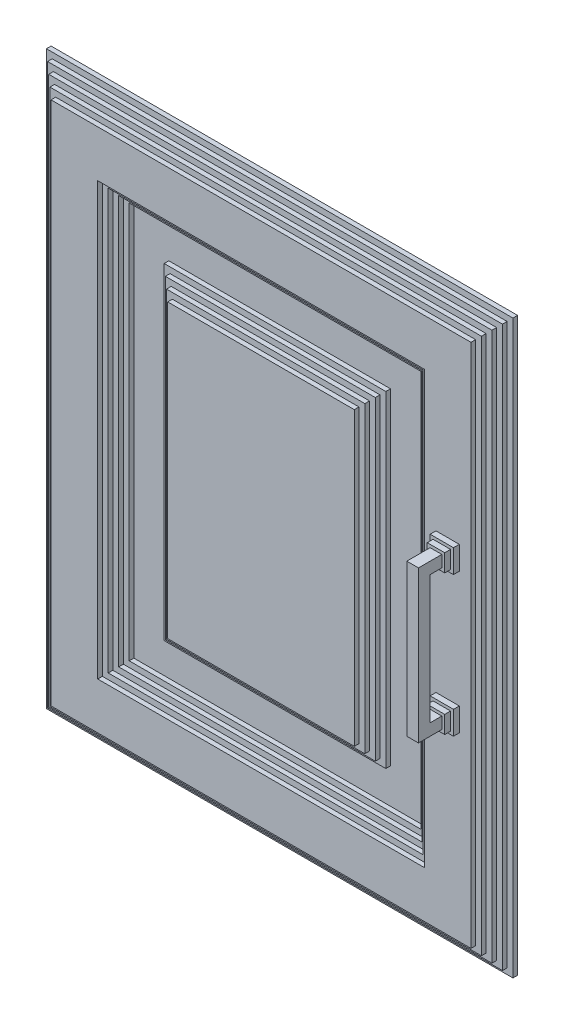
from build123d import *

# Parameters (mm, degrees)
BOSS_EXTRUDE2_DEPTH  = 4
SKETCH2_W            = 390
SKETCH2_H            = 480
BOSS_EXTRUDE3_DEPTH  = 4
SKETCH3_W            = 380
SKETCH3_H            = 470
BOSS_EXTRUDE4_DEPTH  = 4
SKETCH4_W            = 370
SKETCH4_H            = 460
BOSS_EXTRUDE5_DEPTH  = 4
SKETCH5_W            = 360
SKETCH5_H            = 450
BOSS_EXTRUDE6_DEPTH  = 4
SKETCH6_W            = 280
SKETCH6_H            = 370
CUT_EXTRUDE1_DEPTH   = 4
SKETCH7_W            = 270
SKETCH7_H            = 360
CUT_EXTRUDE2_DEPTH   = 4
SKETCH8_W            = 260
SKETCH8_H            = 350
CUT_EXTRUDE3_DEPTH   = 4
SKETCH9_W            = 250
SKETCH9_H            = 340
CUT_EXTRUDE4_DEPTH   = 4
SKETCH11_W           = 190
SKETCH11_H           = 280
BOSS_EXTRUDE7_DEPTH  = 4
SKETCH12_W           = 180
SKETCH12_H           = 270
BOSS_EXTRUDE8_DEPTH  = 4
SKETCH13_W           = 170
SKETCH13_H           = 260
BOSS_EXTRUDE9_DEPTH  = 4
SKETCH14_W           = 160
SKETCH14_H           = 250
BOSS_EXTRUDE10_DEPTH = 4
SKETCH15_W           = 20
SKETCH15_H           = 20
BOSS_EXTRUDE11_DEPTH = 5
SKETCH16_W           = 15
SKETCH16_H           = 15
BOSS_EXTRUDE12_DEPTH = 5
SKETCH17_W           = 10
SKETCH17_H           = 10
BOSS_EXTRUDE13_DEPTH = 20
BOSS_EXTRUDE14_REACH = 302
SKETCH18_W           = 10
SKETCH18_H           = 10
CUT_EXTRUDE6_DEPTH   = 3


with BuildPart() as part:
    # Sketch1 → Boss-Extrude2 (new body)
    with BuildSketch(Plane.XY):
        Polygon((200, 0), (200, -20), (200, -245), (-200, -245), (-200, -20), (-200, 0), (-200, 245), (200, 245), align=None)
    extrude(amount=BOSS_EXTRUDE2_DEPTH)

    # Sketch2 → Boss-Extrude3 (add)
    with BuildSketch(Plane.XY.offset(4)):
        Rectangle(SKETCH2_W, SKETCH2_H)
    extrude(amount=BOSS_EXTRUDE3_DEPTH)

    # Sketch3 → Boss-Extrude4 (add)
    with BuildSketch(Plane.XY.offset(8)):
        Rectangle(SKETCH3_W, SKETCH3_H)
    extrude(amount=BOSS_EXTRUDE4_DEPTH)

    # Sketch4 → Boss-Extrude5 (add)
    with BuildSketch(Plane.XY.offset(12)):
        Rectangle(SKETCH4_W, SKETCH4_H)
    extrude(amount=BOSS_EXTRUDE5_DEPTH)

    # Sketch5 → Boss-Extrude6 (add)
    with BuildSketch(Plane.XY.offset(16)):
        Rectangle(SKETCH5_W, SKETCH5_H)
    extrude(amount=BOSS_EXTRUDE6_DEPTH)

    # Sketch6 → Cut-Extrude1 (cut)
    with BuildSketch(Plane.XY.offset(20)):
        Rectangle(SKETCH6_W, SKETCH6_H)
    extrude(amount=-CUT_EXTRUDE1_DEPTH, mode=Mode.SUBTRACT)

    # Sketch7 → Cut-Extrude2 (cut)
    with BuildSketch(Plane.XY.offset(16)):
        Rectangle(SKETCH7_W, SKETCH7_H)
    extrude(amount=-CUT_EXTRUDE2_DEPTH, mode=Mode.SUBTRACT)

    # Sketch8 → Cut-Extrude3 (cut)
    with BuildSketch(Plane.XY.offset(12)):
        Rectangle(SKETCH8_W, SKETCH8_H)
    extrude(amount=-CUT_EXTRUDE3_DEPTH, mode=Mode.SUBTRACT)

    # Sketch9 → Cut-Extrude4 (cut)
    with BuildSketch(Plane.XY.offset(8)):
        Rectangle(SKETCH9_W, SKETCH9_H)
    extrude(amount=-CUT_EXTRUDE4_DEPTH, mode=Mode.SUBTRACT)

    # Sketch11 → Boss-Extrude7 (add)
    with BuildSketch(Plane.XY.offset(4)):
        Rectangle(SKETCH11_W, SKETCH11_H)
    extrude(amount=BOSS_EXTRUDE7_DEPTH)

    # Sketch12 → Boss-Extrude8 (add)
    with BuildSketch(Plane.XY.offset(8)):
        Rectangle(SKETCH12_W, SKETCH12_H)
    extrude(amount=BOSS_EXTRUDE8_DEPTH)

    # Sketch13 → Boss-Extrude9 (add)
    with BuildSketch(Plane.XY.offset(12)):
        Rectangle(SKETCH13_W, SKETCH13_H)
    extrude(amount=BOSS_EXTRUDE9_DEPTH)

    # Sketch14 → Boss-Extrude10 (add)
    with BuildSketch(Plane.XY.offset(16)):
        Rectangle(SKETCH14_W, SKETCH14_H)
    extrude(amount=BOSS_EXTRUDE10_DEPTH)

    # Sketch15 → Boss-Extrude11 (add)
    with BuildSketch(Plane.XY.offset(20)):
        with Locations((160, 60)):
            Rectangle(SKETCH15_W, SKETCH15_H)
        with Locations((160, -60)):
            Rectangle(SKETCH15_W, SKETCH15_H)
    extrude(amount=BOSS_EXTRUDE11_DEPTH)

    # Sketch16 → Boss-Extrude12 (add)
    with BuildSketch(Plane.XY.offset(25)):
        with Locations((160, 60)):
            Rectangle(SKETCH16_W, SKETCH16_H)
        with Locations((160, -60)):
            Rectangle(SKETCH16_W, SKETCH16_H)
    extrude(amount=BOSS_EXTRUDE12_DEPTH)

    # Sketch17 → Boss-Extrude13 (add)
    with BuildSketch(Plane.XY.offset(30)):
        with Locations((160, 60)):
            Rectangle(SKETCH17_W, SKETCH17_H)
        with Locations((160, -60)):
            Rectangle(SKETCH17_W, SKETCH17_H)
    extrude(amount=BOSS_EXTRUDE13_DEPTH)

    # Sketch18 → Boss-Extrude14 (add, up to next)
    with BuildSketch(Plane.XZ.offset(-55), mode=Mode.PRIVATE) as boss_extrude14_sk1:
        with Locations((160, 45)):
            Rectangle(SKETCH18_W, SKETCH18_H)
    boss_extrude14_tool1 = extrude(boss_extrude14_sk1.sketch, amount=BOSS_EXTRUDE14_REACH, mode=Mode.PRIVATE) - part.part
    add(boss_extrude14_tool1.solids().sort_by_distance((160, 55, 45))[0])

    # Sketch19 → Cut-Extrude6 (cut)
    with BuildSketch(Plane(origin=(0, 0, 0), x_dir=(-1, 0, 0), z_dir=(0, 0, -1))):
        with BuildLine():
            Line((165, 191.875), (165, 101.875))
            ThreePointArc((165, 101.875), (180, 91.875), (195, 101.875))
            Line((195, 101.875), (195, 141.875))
            Line((195, 141.875), (200, 141.875))
            Line((200, 141.875), (200, 191.875))
            Line((200, 191.875), (165, 191.875))
        make_face()
        with BuildLine():
            Line((165, -108.125), (165, -198.125))
            ThreePointArc((165, -198.125), (180, -208.125), (195, -198.125))
            Line((195, -198.125), (195, -158.125))
            Line((195, -158.125), (200, -158.125))
            Line((200, -158.125), (200, -108.125))
            Line((200, -108.125), (165, -108.125))
        make_face()
    extrude(amount=-CUT_EXTRUDE6_DEPTH, mode=Mode.SUBTRACT)


solid = part.part
